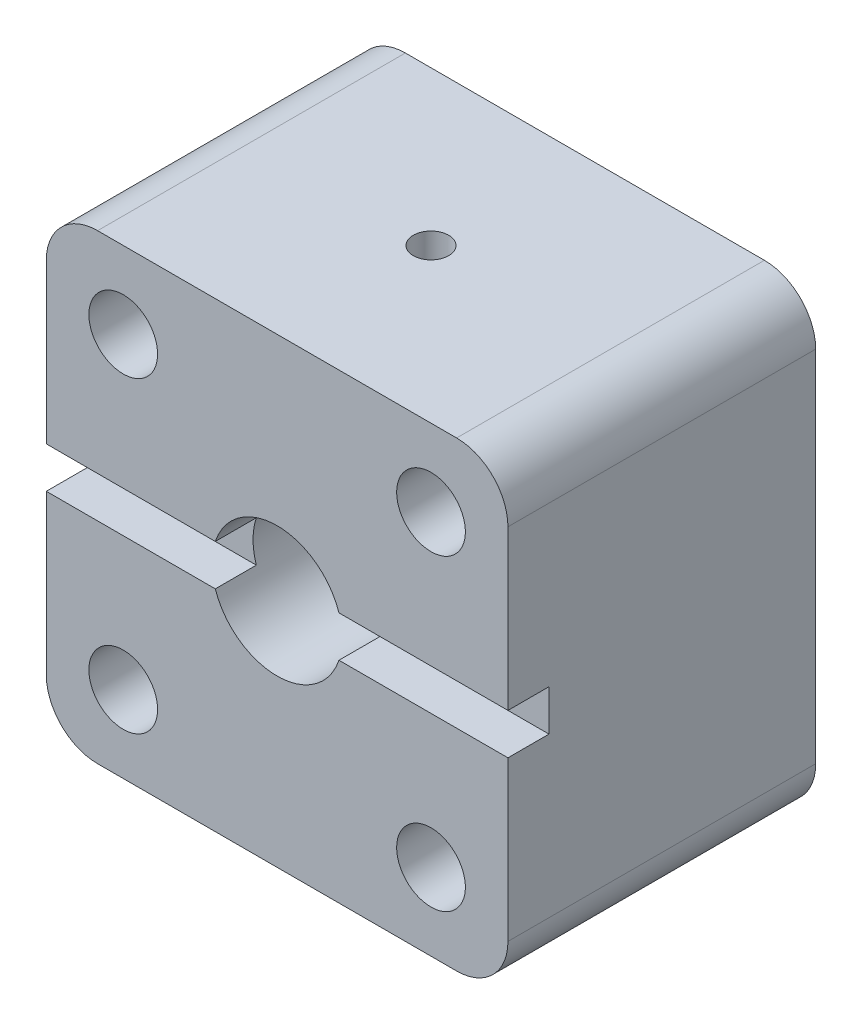
from build123d import *

# Parameters (mm, degrees)
SKETCH1_W                  = 45
SKETCH1_H                  = 45
BOSS_EXTRUDE1_DEPTH        = 30
SKETCH2_R                  = 3.35
CUT_EXTRUDE1_DEPTH         = 31
SKETCH3_W                  = 4
SKETCH3_H                  = 4
PIEZOWIREFEEDTHROUGH_DEPTH = 46
ALIGNMENTHOLE_D            = 3.4544
ALIGNMENTHOLE_DEPTH        = 10
ALIGNMENTHOLE_TIP          = 1.037806461
F_0_535_40_TAPPED_HOLE1_D  = 12.7
FILLET1_R                  = 5


with BuildPart() as part:
    # Sketch1 → Boss-Extrude1 (new body)
    with BuildSketch(Plane.XY):
        with Locations((22.5, 22.5)):
            Rectangle(SKETCH1_W, SKETCH1_H)
    extrude(amount=BOSS_EXTRUDE1_DEPTH)

    # Sketch2 → Cut-Extrude1 (cut, through all)
    with BuildSketch(Plane(origin=(0, 0, 0), x_dir=(-1, 0, 0), z_dir=(0, 0, -1))):
        with Locations((-37.5, 37.5)):
            Circle(SKETCH2_R)
        with Locations((-7.5, 37.5)):
            Circle(SKETCH2_R)
        with Locations((-37.5, 7.5)):
            Circle(SKETCH2_R)
        with Locations((-7.5, 7.5)):
            Circle(SKETCH2_R)
    extrude(amount=-CUT_EXTRUDE1_DEPTH, mode=Mode.SUBTRACT)

    # Sketch3 → PiezoWireFeedthrough (cut, through all)
    with BuildSketch(Plane(origin=(45, 0, 0), x_dir=(0, 0, -1), z_dir=(1, 0, 0))):
        with Locations((-28, 22.5)):
            Rectangle(SKETCH3_W, SKETCH3_H)
    extrude(amount=-PIEZOWIREFEEDTHROUGH_DEPTH, mode=Mode.SUBTRACT)

    # AlignmentHole
    with Locations(Plane(origin=(0, 45, 0), x_dir=(1, 0, 0), z_dir=(0, 1, 0))):
        with Locations((22.5, -15)):
            Hole(ALIGNMENTHOLE_D / 2, depth=ALIGNMENTHOLE_DEPTH)
            with Locations((0, 0, -(ALIGNMENTHOLE_DEPTH + ALIGNMENTHOLE_TIP / 2))):  # 118° drill point
                Cone(0, ALIGNMENTHOLE_D / 2, ALIGNMENTHOLE_TIP, mode=Mode.SUBTRACT)

    # 0.535-40 Tapped Hole1 (through all)
    with Locations(Plane(origin=(0, 0, 0), x_dir=(-1, 0, 0), z_dir=(0, 0, -1))):
        with Locations((-22.5, 22.5)):
            Hole(F_0_535_40_TAPPED_HOLE1_D / 2)

    # Fillet1
    fillet1_edges = [part.edges().sort_by_distance(p)[0] for p in [
        (0, 45, 15),
        (45, 45, 15),
        (45, 0, 15),
        (0, 0, 15),
    ]]
    fillet(fillet1_edges, radius=FILLET1_R)


solid = part.part
